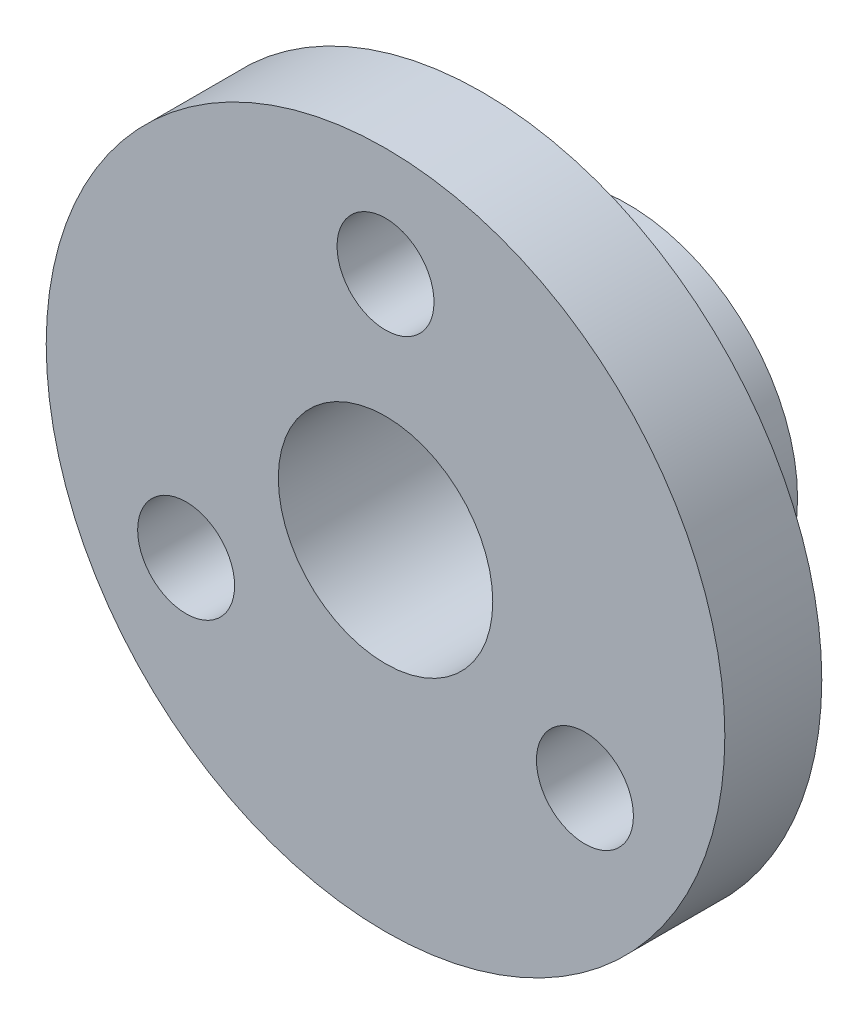
from build123d import *

# Parameters (mm, degrees)
IZIM1_R                     = 7
IZIM1_R_2                   = 2.212355073
Y_KSEKLIK_EKSTR_ZYON1_DEPTH = 2
IZIM2_R                     = 3.5
IZIM2_R_2                   = 2.212355073
Y_KSEKLIK_EKSTR_ZYON2_DEPTH = 5
IZIM3_R                     = 1
KES_EKSTR_ZYON1_DEPTH       = 5


with BuildPart() as part:
    # Çizim1 → Yükseklik-Ekstrüzyon1 (new body)
    with BuildSketch(Plane.XY):
        with Locations((-30.711927379, -38.904760786)):
            Circle(IZIM1_R)
        with Locations((-30.711927379, -38.904760786)):
            Circle(IZIM1_R_2, mode=Mode.SUBTRACT)
    extrude(amount=Y_KSEKLIK_EKSTR_ZYON1_DEPTH)

    # Çizim2 → Yükseklik-Ekstrüzyon2 (add)
    with BuildSketch(Plane.XY.offset(2)):
        with Locations((-30.711927379, -38.904760786)):
            Circle(IZIM2_R)
        with Locations((-30.711927379, -38.904760786)):
            Circle(IZIM2_R_2, mode=Mode.SUBTRACT)
    extrude(amount=-Y_KSEKLIK_EKSTR_ZYON2_DEPTH)

    # Çizim3 → Kes-Ekstrüzyon1 (cut)
    with BuildSketch(Plane(origin=(0, 0, 0), x_dir=(-1, 0, 0), z_dir=(0, 0, -1))):
        with Locations((30.711927379, -34.154760786)):
            Circle(IZIM3_R)
        with Locations((34.825548047, -41.279760786)):
            Circle(IZIM3_R)
        with Locations((26.598306711, -41.279760786)):
            Circle(IZIM3_R)
    extrude(amount=-KES_EKSTR_ZYON1_DEPTH, mode=Mode.SUBTRACT)


solid = part.part
